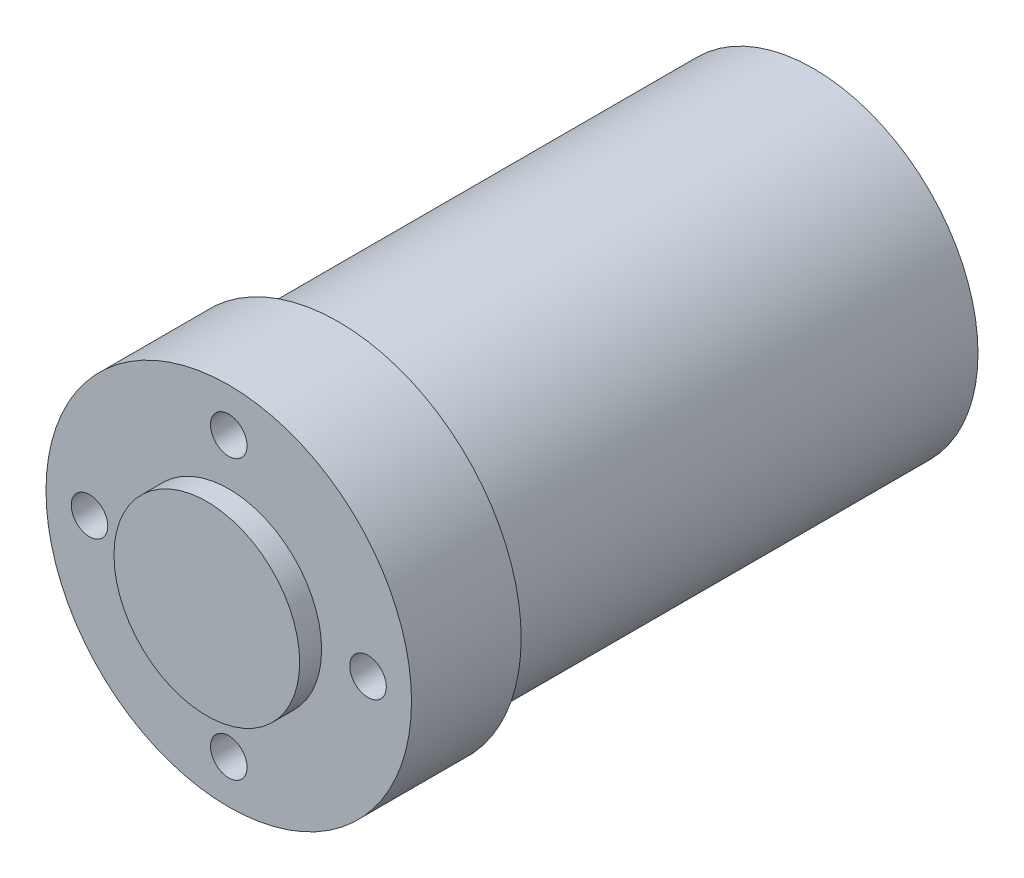
from build123d import *

# Parameters (mm, degrees)
SKETCH1_W                  = 25
SKETCH1_H                  = 15
SKETCH2_R                  = 12.7
BOSS_EXTRUDE1_DEPTH        = 3
SKETCH3_R                  = 22.4917
BOSS_EXTRUDE2_DEPTH        = 65
F_10_CLEARANCE_HOLE1_D     = 5
F_10_CLEARANCE_HOLE1_DEPTH = 8
F_10_CLEARANCE_HOLE2_D     = 5
F_10_CLEARANCE_HOLE2_DEPTH = 12.446


with BuildPart() as part:
    # Sketch1 → Revolve1 (revolve)
    with BuildSketch(Plane.XZ):
        with Locations((12.5, 72.5)):
            Rectangle(SKETCH1_W, SKETCH1_H)
    revolve(axis=Axis((0, 0, 80), (0, 0, -1)))

    # Sketch2 → Boss-Extrude1 (add)
    with BuildSketch(Plane.XY.offset(80)):
        Circle(SKETCH2_R)
    extrude(amount=BOSS_EXTRUDE1_DEPTH)

    # Sketch3 → Boss-Extrude2 (add)
    with BuildSketch(Plane(origin=(0, 0, 65), x_dir=(-1, 0, 0), z_dir=(0, 0, -1))):
        Circle(SKETCH3_R)
    extrude(amount=BOSS_EXTRUDE2_DEPTH)

    # #10 Clearance Hole1
    with Locations(Plane(origin=(0, 0, 0), x_dir=(-1, 0, 0), z_dir=(0, 0, -1))):
        with Locations((-12.374368671, 12.374368671), (-17.5, 0), (-12.374368671, -12.374368671), (0, -17.5), (12.374368671, -12.374368671), (17.5, 0), (12.374368671, 12.374368671), (0, 17.5)):
            Hole(F_10_CLEARANCE_HOLE1_D / 2, depth=F_10_CLEARANCE_HOLE1_DEPTH)

    # #10 Clearance Hole2
    with Locations(Plane.XY.offset(80)):
        with Locations((-19.05, 0), (0, -19.05), (19.05, 0), (0, 19.05)):
            Hole(F_10_CLEARANCE_HOLE2_D / 2, depth=F_10_CLEARANCE_HOLE2_DEPTH)


solid = part.part
